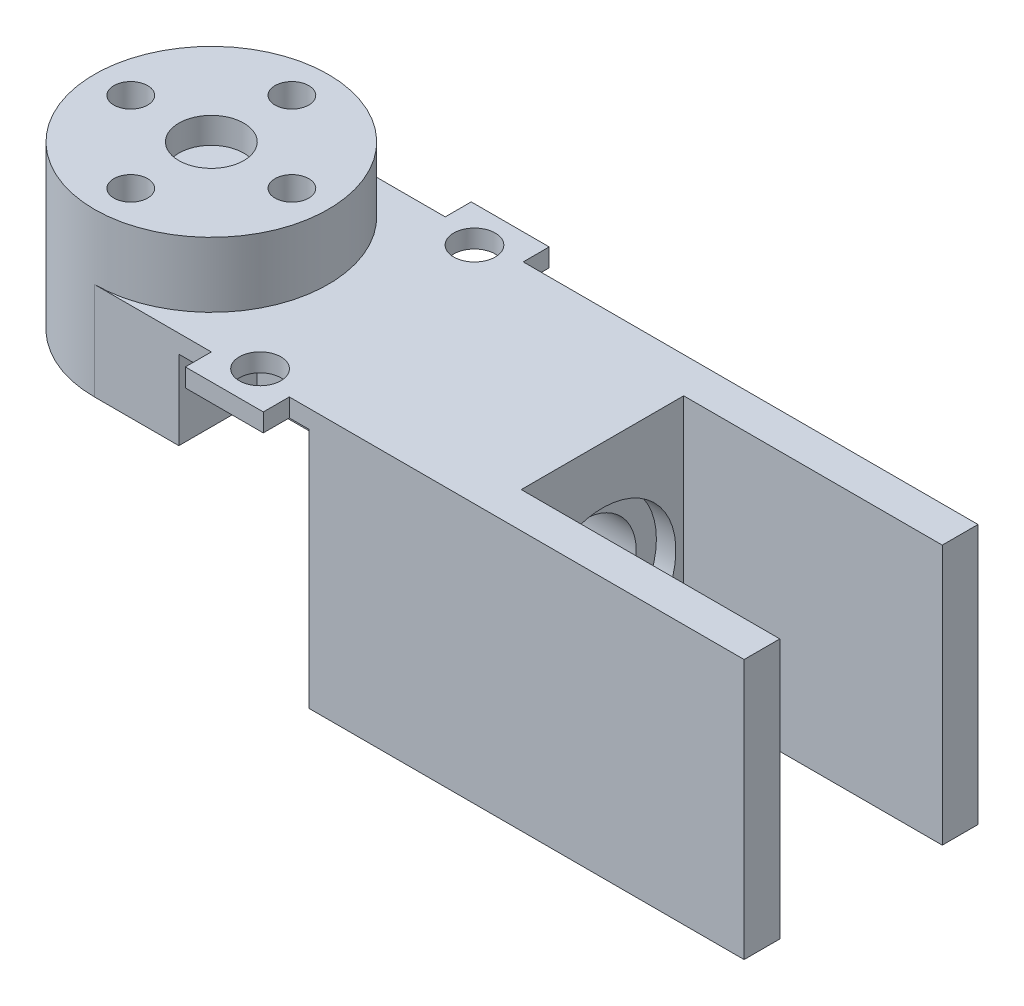
from build123d import *

# Parameters (mm, degrees)
SKETCH1_R                = 9
BOSS_EXTRUDE1_DEPTH      = 25
SKETCH2_R                = 2.4
CUT_EXTRUDE1_DEPTH       = 22
SKETCH4_R                = 1.3
CUT_EXTRUDE2_DEPTH       = 26
SKETCH19_R               = 2.5
CUT_EXTRUDE10_DEPTH      = 2
BOSS_EXTRUDE2_DEPTH      = 20
SKETCH8_R                = 5.65
CUT_EXTRUDE3_DEPTH       = 20.9
CUT_EXTRUDE3_DEPTH_BACK  = 1.5
CUT_EXTRUDE5_DEPTH       = 12.5
FILLET1_R                = 5
SKETCH11_R               = 4.1
CUT_EXTRUDE6_DEPTH       = 7
FILLET4_R                = 0.5
SKETCH12_W               = 6
SKETCH12_H               = 1.4
BOSS_EXTRUDE3_DEPTH      = 2
BOSS_EXTRUDE3_DEPTH_BACK = 20
SKETCH13_R               = 1.6
CUT_EXTRUDE7_DEPTH       = 21
SKETCH14_W               = 10
SKETCH14_H               = 18.6
CUT_EXTRUDE8_DEPTH       = 6
SKETCH15_W               = 10
SKETCH15_H               = 18.6
CUT_EXTRUDE9_DEPTH       = 6
CUT_EXTRUDE11_REACH      = 16
SKETCH20_W               = 10
SKETCH20_H               = 12.5


with BuildPart() as part:
    # Sketch1 → Boss-Extrude1 (new body)
    with BuildSketch(Plane(origin=(0, 0, 0), x_dir=(1, 0, 0), z_dir=(0, 1, 0))):
        Circle(SKETCH1_R)
    extrude(amount=BOSS_EXTRUDE1_DEPTH)

    # Sketch2 → Cut-Extrude1 (cut)
    with BuildSketch(Plane.XZ):
        with Locations((0, 6.2)):
            Circle(SKETCH2_R)
        with Locations((6.2, 0)):
            Circle(SKETCH2_R)
        with Locations((0, -6.2)):
            Circle(SKETCH2_R)
        with Locations((-6.2, 0)):
            Circle(SKETCH2_R)
    extrude(amount=-CUT_EXTRUDE1_DEPTH, mode=Mode.SUBTRACT)

    # Sketch4 → Cut-Extrude2 (cut, through all)
    with BuildSketch(Plane.XZ):
        with Locations((0, 6.2)):
            Circle(SKETCH4_R)
        with Locations((6.2, 0)):
            Circle(SKETCH4_R)
        with Locations((0, -6.2)):
            Circle(SKETCH4_R)
        with Locations((-6.2, 0)):
            Circle(SKETCH4_R)
    extrude(amount=-CUT_EXTRUDE2_DEPTH, mode=Mode.SUBTRACT)

    # Sketch19 → Cut-Extrude10 (cut)
    with BuildSketch(Plane(origin=(0, 25, 0), x_dir=(1, 0, 0), z_dir=(0, 1, 0))):
        Circle(SKETCH19_R)
    extrude(amount=-CUT_EXTRUDE10_DEPTH, mode=Mode.SUBTRACT)

    # Sketch6 → Boss-Extrude2 (add)
    with BuildSketch(Plane(origin=(0, 0, 0), x_dir=(1, 0, 0), z_dir=(0, 1, 0))):
        with BuildLine():
            Line((30.1, 6.25), (50, 6.25))
            Line((50, 6.25), (50, 9))
            Line((50, 9), (0, 9))
            ThreePointArc((0, 9), (9, 0), (0, -9))
            Line((0, -9), (50, -9))
            Line((50, -9), (50, -6.25))
            Line((50, -6.25), (30.1, -6.25))
            Line((30.1, -6.25), (30.1, 6.25))
        make_face()
    extrude(amount=BOSS_EXTRUDE2_DEPTH)

    # Sketch8 → Cut-Extrude3 (cut, two sides)
    with BuildSketch(Plane(origin=(30.1, 0, 0), x_dir=(0, 0, -1), z_dir=(1, 0, 0))) as cut_extrude3_sk:
        with Locations((0, 10)):
            Circle(SKETCH8_R)
    extrude(amount=CUT_EXTRUDE3_DEPTH, mode=Mode.SUBTRACT)
    extrude(cut_extrude3_sk.sketch, amount=-CUT_EXTRUDE3_DEPTH_BACK, mode=Mode.SUBTRACT)

    # Sketch10 → Cut-Extrude5 (cut)
    with BuildSketch(Plane.XZ):
        with BuildLine():
            Line((9, 0), (9, 9))
            Line((9, 9), (0, 9))
            ThreePointArc((0, 9), (-9, 0), (0, -9))
            Line((0, -9), (9, -9))
            Line((9, -9), (9, 0))
        make_face()
    extrude(amount=-CUT_EXTRUDE5_DEPTH, mode=Mode.SUBTRACT)

    # Fillet1
    fillet1_edges = [part.edges().sort_by_distance(p)[0] for p in [
        (9, 0, 0),
    ]]
    fillet(fillet1_edges, radius=FILLET1_R)

    # Sketch11 → Cut-Extrude6 (cut)
    with BuildSketch(Plane(origin=(28.6, 0, 0), x_dir=(0, 0, -1), z_dir=(1, 0, 0))):
        with Locations((0, 10)):
            Circle(SKETCH11_R)
    extrude(amount=-CUT_EXTRUDE6_DEPTH, mode=Mode.SUBTRACT)

    # Fillet4
    fillet4_edges = [part.edges().sort_by_distance(p)[0] for p in [
        (9, 12.5, 0),
    ]]
    fillet(fillet4_edges, radius=FILLET4_R)

    # Sketch12 → Boss-Extrude3 (add, two sides)
    with BuildSketch(Plane.XY.offset(9)) as boss_extrude3_sk:
        with Locations((12, 19.3)):
            Rectangle(SKETCH12_W, SKETCH12_H)
    extrude(amount=BOSS_EXTRUDE3_DEPTH)
    extrude(boss_extrude3_sk.sketch, amount=-BOSS_EXTRUDE3_DEPTH_BACK)

    # Sketch13 → Cut-Extrude7 (cut, through all)
    with BuildSketch(Plane(origin=(0, 20, 0), x_dir=(1, 0, 0), z_dir=(0, 1, 0))):
        with Locations((12, 8.25)):
            Circle(SKETCH13_R)
        with Locations((12, -8.25)):
            Circle(SKETCH13_R)
    extrude(amount=-CUT_EXTRUDE7_DEPTH, mode=Mode.SUBTRACT)

    # Sketch14 → Cut-Extrude8 (cut)
    with BuildSketch(Plane.XY.offset(9)):
        with Locations((11.5, 9.3)):
            Rectangle(SKETCH14_W, SKETCH14_H)
    extrude(amount=-CUT_EXTRUDE8_DEPTH, mode=Mode.SUBTRACT)

    # Sketch15 → Cut-Extrude9 (cut)
    with BuildSketch(Plane(origin=(0, 0, -9), x_dir=(-1, 0, 0), z_dir=(0, 0, -1))):
        with Locations((-11.5, 9.3)):
            Rectangle(SKETCH15_W, SKETCH15_H)
    extrude(amount=-CUT_EXTRUDE9_DEPTH, mode=Mode.SUBTRACT)

    # Sketch20 → Cut-Extrude11 (cut, up to next)
    with BuildSketch(Plane(origin=(0, 0, -3), x_dir=(-1, 0, 0), z_dir=(0, 0, -1)), mode=Mode.PRIVATE) as cut_extrude11_sk1:
        with Locations((-11.5, 6.25)):
            Rectangle(SKETCH20_W, SKETCH20_H)
    cut_extrude11_tool1 = extrude(cut_extrude11_sk1.sketch, amount=-CUT_EXTRUDE11_REACH, mode=Mode.PRIVATE) & part.part
    add(cut_extrude11_tool1.solids().sort_by_distance((11.5, 6.25, -3))[0], mode=Mode.SUBTRACT)


solid = part.part
